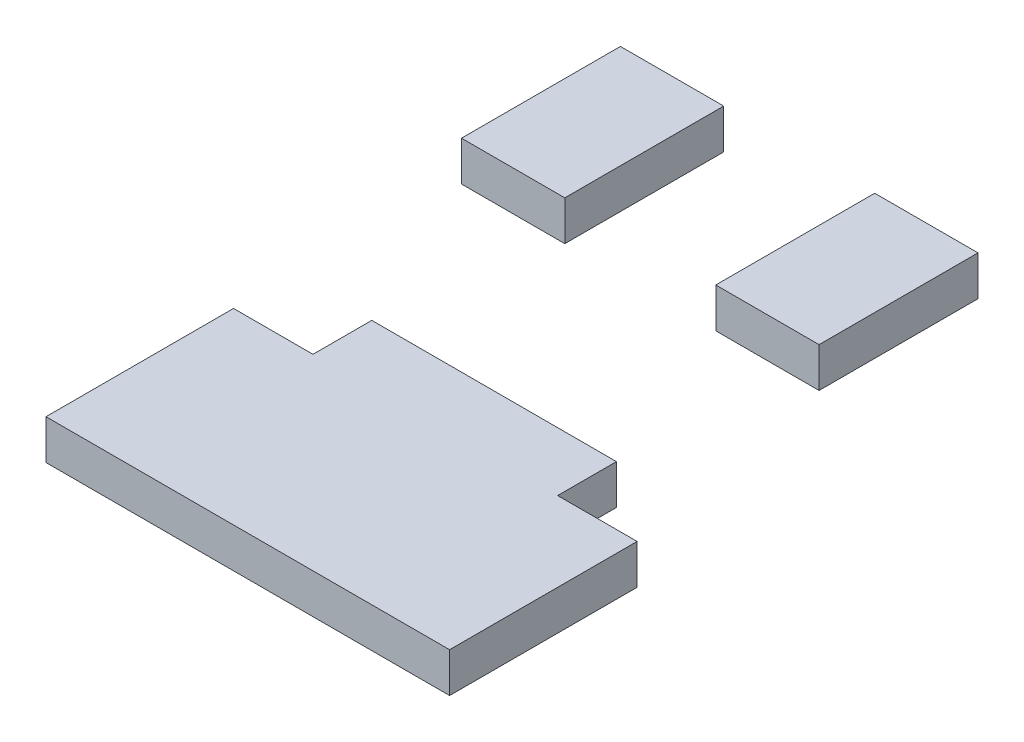
from build123d import *

# Parameters (mm, degrees)
BOSS_EXTRUDE1_DEPTH   = 5
SKETCH1_W             = 13
SKETCH1_H             = 20
BOSS_EXTRUDE1_2_DEPTH = 5
BOSS_EXTRUDE1_3_DEPTH = 5


with BuildPart() as part:
    # Sketch1 → Boss-Extrude1 (new body)
    with BuildSketch(Plane(origin=(0, 0, 0), x_dir=(1, 0, 0), z_dir=(0, 1, 0))):
        Polygon((-15.28967138, -6.526896022), (-25.28967138, -6.526896022), (-25.28967138, -30.126896022), (25.5, -30.126896022), (25.5, -6.526896022), (15.5, -6.526896022), (15.5, 0.873103978), (-15.28967138, 0.873103978), align=None)
    extrude(amount=BOSS_EXTRUDE1_DEPTH)


with BuildPart() as body_2:
    # Sketch1 → Boss-Extrude1 2 (new body)
    with BuildSketch(Plane(origin=(0, 0, 0), x_dir=(1, 0, 0), z_dir=(0, 1, 0))):
        with Locations((-23, 36.373103978)):
            Rectangle(SKETCH1_W, SKETCH1_H)
    extrude(amount=BOSS_EXTRUDE1_2_DEPTH)


with BuildPart() as body_3:
    # Sketch1 → Boss-Extrude1 3 (new body)
    with BuildSketch(Plane(origin=(0, 0, 0), x_dir=(1, 0, 0), z_dir=(0, 1, 0))):
        with Locations((9, 36.373103978)):
            Rectangle(SKETCH1_W, SKETCH1_H)
    extrude(amount=BOSS_EXTRUDE1_3_DEPTH)


solid = Compound([part.part, body_2.part, body_3.part])
